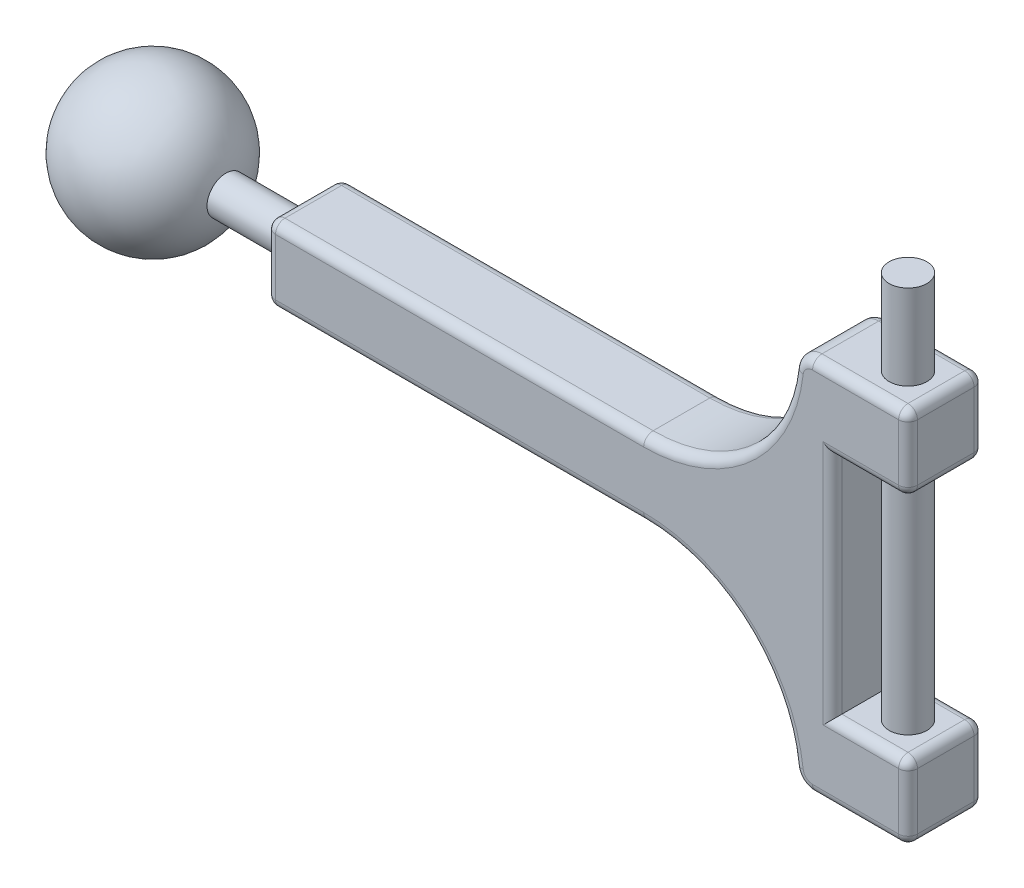
from build123d import *

# Parameters (mm, degrees)
BOSS_EXTRUDE2_DEPTH = 10
SKETCH2_R           = 2.5
BOSS_EXTRUDE3_DEPTH = 20
SKETCH5_R           = 2.5
BOSS_EXTRUDE4_DEPTH = 30
SKETCH6_R           = 2.5
BOSS_EXTRUDE5_DEPTH = 11.25
FILLET1_R           = 1.25


with BuildPart() as part:
    # Sketch1 → Boss-Extrude2 (new body)
    with BuildSketch(Plane.XY):
        with BuildLine():
            Line((-80, 5), (-30, 5))
            ThreePointArc((-30, 5), (-16.666666667, 10.09288015), (-10.1238402, 22.777777778))
            ThreePointArc((-10.1238402, 22.777777778), (-9.305986892, 24.363389981), (-7.639320225, 25))
            Line((-7.639320225, 25), (5, 25))
            Line((5, 25), (5, 15))
            Line((5, 15), (-5, 15))
            Line((-5, 15), (-5, -15))
            Line((-5, -15), (5, -15))
            Line((5, -15), (5, -25))
            Line((5, -25), (-7.639320225, -25))
            ThreePointArc((-7.639320225, -25), (-9.305986892, -24.363389981), (-10.1238402, -22.777777778))
            ThreePointArc((-10.1238402, -22.777777778), (-16.666666667, -10.09288015), (-30, -5))
            Line((-30, -5), (-80, -5))
            Line((-80, -5), (-80, 5))
        make_face()
    extrude(amount=BOSS_EXTRUDE2_DEPTH)

    # Sketch2 → Boss-Extrude3 (add)
    with BuildSketch(Plane.ZY.offset(80)):
        with Locations((5, 0)):
            Circle(SKETCH2_R)
    extrude(amount=BOSS_EXTRUDE3_DEPTH)

    # Sketch3 → Revolve1 (revolve)
    with BuildSketch(Plane.ZY.offset(100)):
        with BuildLine():
            Line((5, 10), (5, -10))
            ThreePointArc((5, -10), (-5, 0), (5, 10))
        make_face()
    revolve(axis=Axis((-100, 10, 5), (0, -1, 0)))

    # Sketch5 → Boss-Extrude4 (add)
    with BuildSketch(Plane.XZ.offset(-15)):
        with Locations((0, 5)):
            Circle(SKETCH5_R)
    extrude(amount=BOSS_EXTRUDE4_DEPTH)

    # Sketch6 → Boss-Extrude5 (add)
    with BuildSketch(Plane(origin=(0, 25, 0), x_dir=(1, 0, 0), z_dir=(0, 1, 0))):
        with Locations((0, -5)):
            Circle(SKETCH6_R)
    extrude(amount=BOSS_EXTRUDE5_DEPTH)

    # Fillet1
    fillet1_edges = [part.edges().sort_by_distance(p)[0] for p in [
        (-16.666666667, -10.09288015, 10),
        (-55, 5, 0),
        (-16.666666667, 10.09288015, 0),
        (-9.305986892, 24.363389981, 0),
        (-1.319660113, 25, 0),
        (5, 20, 0),
        (0, 15, 0),
        (-5, 0, 0),
        (0, -15, 0),
        (-9.305986892, -24.363389981, 10),
        (5, -20, 0),
        (-1.319660113, -25, 0),
        (-9.305986892, -24.363389981, 0),
        (-16.666666667, -10.09288015, 0),
        (-55, -5, 0),
        (-80, 0, 0),
        (-1.319660113, -25, 10),
        (-80, 5, 5),
        (5, 25, 5),
        (5, 15, 5),
        (5, -15, 5),
        (5, -25, 5),
        (5, -20, 10),
        (-80, -5, 5),
        (0, -15, 10),
        (-5, 0, 10),
        (0, 15, 10),
        (5, 20, 10),
        (-1.319660113, 25, 10),
        (-9.305986892, 24.363389981, 10),
        (-80, 0, 10),
        (-16.666666667, 10.09288015, 10),
        (-55, 5, 10),
        (-55, -5, 10),
    ]]
    fillet(fillet1_edges, radius=FILLET1_R)


solid = part.part
